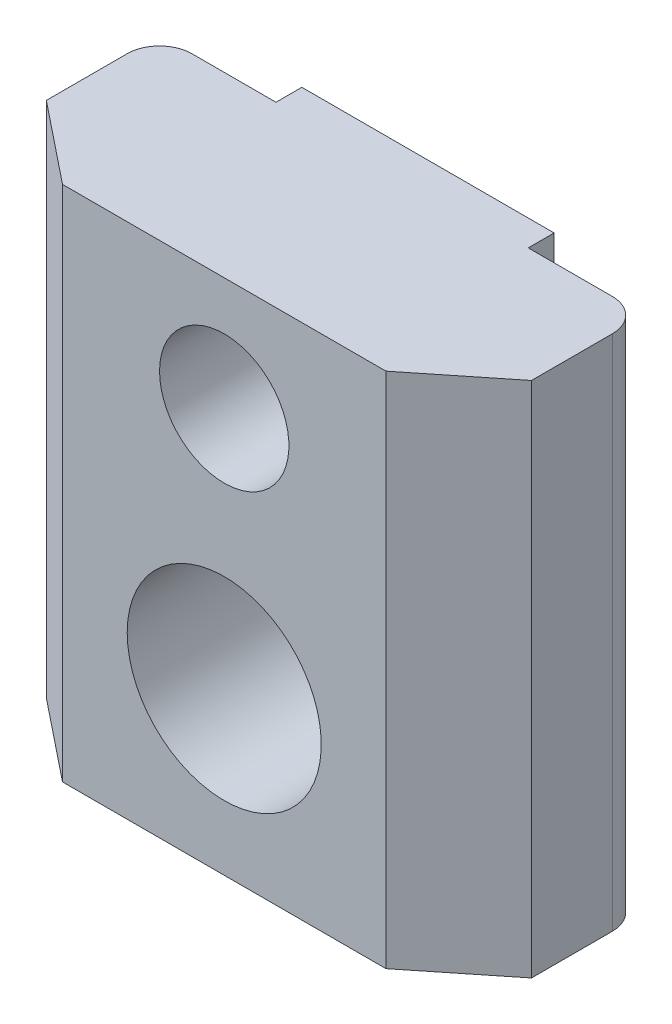
from build123d import *

# Parameters (mm, degrees)
BOSS_EXTRUDE1_DEPTH      = 11
BOSS_EXTRUDE1_DEPTH_BACK = 5
SKETCH2_R                = 3
SKETCH2_R_2              = 2
CUT_EXTRUDE1_DEPTH       = 7.3
FILLET1_R                = 1


with BuildPart() as part:
    # Sketch1 → Boss-Extrude1 (new body, two sides)
    with BuildSketch(Plane(origin=(0, 0, 0), x_dir=(1, 0, 0), z_dir=(0, 1, 0))) as boss_extrude1_sk:
        Polygon((-3.9, 0.8), (3.9, 0.8), (3.9, 0), (7.5, 0), (7.5, -3.5), (5, -5.5), (-5, -5.5), (-7.5, -3.5), (-7.5, 0), (-3.9, 0), align=None)
    extrude(amount=BOSS_EXTRUDE1_DEPTH)
    extrude(boss_extrude1_sk.sketch, amount=-BOSS_EXTRUDE1_DEPTH_BACK)

    # Sketch2 → Cut-Extrude1 (cut, through all)
    with BuildSketch(Plane(origin=(0, 0, -0.8), x_dir=(-1, 0, 0), z_dir=(0, 0, -1))):
        Circle(SKETCH2_R)
        with Locations((0, 7.5)):
            Circle(SKETCH2_R_2)
    extrude(amount=-CUT_EXTRUDE1_DEPTH, mode=Mode.SUBTRACT)

    # Fillet1
    fillet1_edges = [part.edges().sort_by_distance(p)[0] for p in [
        (7.5, 3, 0),
        (-7.5, 3, 0),
    ]]
    fillet(fillet1_edges, radius=FILLET1_R)


solid = part.part
